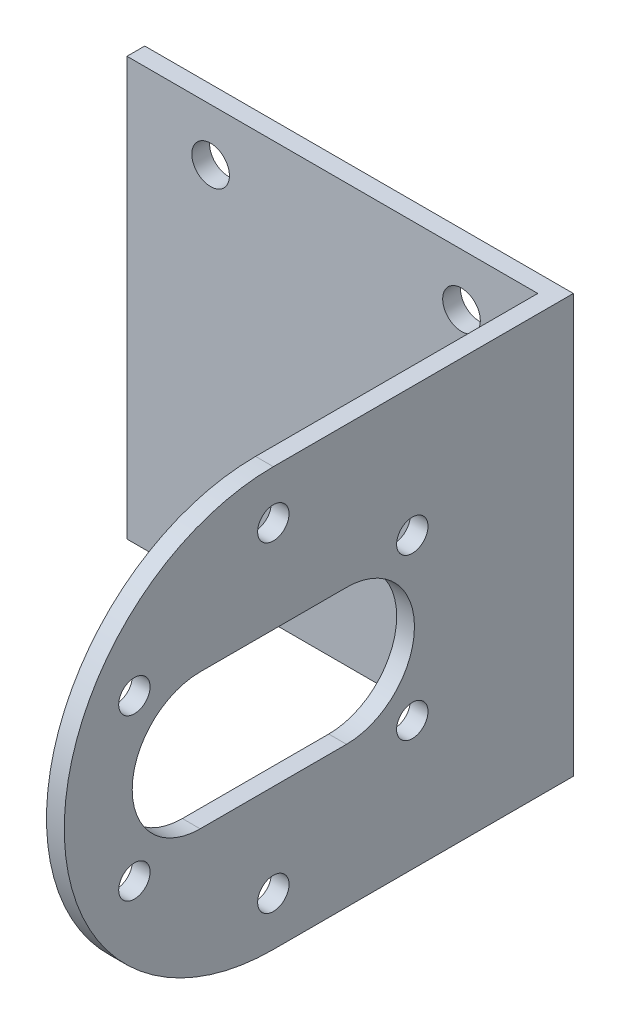
from build123d import *

# Parameters (mm, degrees)
CROQUIS1_R              = 1.8
SALIENTE_EXTRUIR1_DEPTH = 1.7
CROQUIS2_W              = 1.7
CROQUIS2_H              = 40
SALIENTE_EXTRUIR2_DEPTH = 60
CORTAR_EXTRUIR1_DEPTH   = 10
CROQUIS3_4_R            = 1.5
CORTAR_EXTRUIR2_DEPTH   = 10


with BuildPart() as part:
    # Croquis1 → Saliente-Extruir1 (new body)
    with BuildSketch(Plane.XY):
        Polygon((0, 0), (8, 0), (41, 0), (41, 40), (8, 40), (0, 40), align=None)
        with Locations((8, 5)):
            Circle(CROQUIS1_R, mode=Mode.SUBTRACT)
        with Locations((8, 35)):
            Circle(CROQUIS1_R, mode=Mode.SUBTRACT)
        with Locations((32, 5)):
            Circle(CROQUIS1_R, mode=Mode.SUBTRACT)
        with Locations((32, 35)):
            Circle(CROQUIS1_R, mode=Mode.SUBTRACT)
    extrude(amount=SALIENTE_EXTRUIR1_DEPTH)

    # Croquis2 → Saliente-Extruir2 (add)
    with BuildSketch(Plane.XY.offset(1.7)):
        with Locations((40.15, 20)):
            Rectangle(CROQUIS2_W, CROQUIS2_H)
    extrude(amount=SALIENTE_EXTRUIR2_DEPTH)

    # Croquis3 → Cortar-Extruir1 (cut)
    with BuildSketch(Plane.ZY.offset(-39.3)):
        with BuildLine():
            Line((61.7, 40), (28.7, 40))
            ThreePointArc((28.7, 40), (48.7, 20), (28.7, 0))
            Line((28.7, 0), (61.7, 0))
            Line((61.7, 0), (61.7, 40))
        make_face()
        with BuildLine():
            Line((35.7, 26.5), (21.7, 26.5))
            ThreePointArc((21.7, 26.5), (15.2, 20), (21.7, 13.5))
            Line((21.7, 13.5), (35.7, 13.5))
            ThreePointArc((35.7, 13.5), (42.2, 20), (35.7, 26.5))
        make_face()
    extrude(amount=-CORTAR_EXTRUIR1_DEPTH, mode=Mode.SUBTRACT)

    # Croquis3_4 → Cortar-Extruir2 (cut)
    with BuildSketch(Plane.ZY.offset(-39.3)):
        with Locations((41.993489948, 27.675)):
            Circle(CROQUIS3_4_R)
        with Locations((41.993489948, 12.325)):
            Circle(CROQUIS3_4_R)
        with Locations((28.7, 35.35)):
            Circle(CROQUIS3_4_R)
        with Locations((28.7, 4.65)):
            Circle(CROQUIS3_4_R)
        with Locations((15.406510052, 27.675)):
            Circle(CROQUIS3_4_R)
        with Locations((15.406510052, 12.325)):
            Circle(CROQUIS3_4_R)
    extrude(amount=-CORTAR_EXTRUIR2_DEPTH, mode=Mode.SUBTRACT)


solid = part.part
